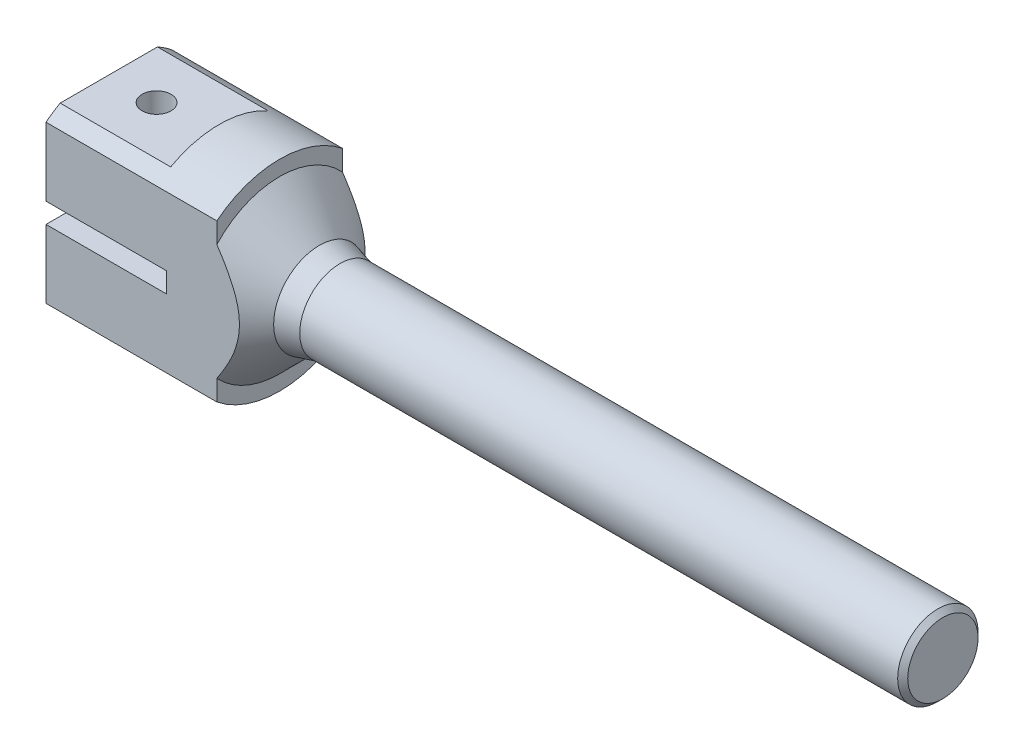
from build123d import *

# Parameters (mm, degrees)
SKIZZE2_W                       = 22
SKIZZE2_H                       = 2.5
SKIZZE2_W_2                     = 24
SKIZZE2_H_2                     = 4
SCHNITT_LINEAR_AUSTRAGEN1_DEPTH = 50
SKIZZE3_R                       = 2.875
SKIZZE3_W                       = 38.5
SKIZZE3_H                       = 7.5
SCHNITT_LINEAR_AUSTRAGEN2_DEPTH = 38.5
FASE1_SIZE                      = 1


with BuildPart() as part:
    # Skizze1 → Rotation1 (revolve)
    with BuildSketch(Plane.XY, mode=Mode.PRIVATE) as rotation1_sk:
        Polygon((0, 0), (0, 8), (-120, 8), (-124.098076211, 9.098076211), (-132, 17), (-132, 20), (-166, 20), (-166, 0), align=None)
    revolve(rotation1_sk.sketch.rotate(Axis((0, 0, 0), (1, 0, 0)), 90), axis=Axis((0, 0, 0), (1, 0, 0)))  # turned: the seam where the file's is

    # Skizze2 → Schnitt-Linear austragen1 (cut, symmetric)
    with BuildSketch(Plane.XY):
        with Locations((-155, 18.75)):
            Rectangle(SKIZZE2_W, SKIZZE2_H)
        with Locations((-154, 0)):
            Rectangle(SKIZZE2_W_2, SKIZZE2_H_2)
        with Locations((-155, -18.75)):
            Rectangle(SKIZZE2_W, SKIZZE2_H)
    extrude(amount=SCHNITT_LINEAR_AUSTRAGEN1_DEPTH, both=True, mode=Mode.SUBTRACT)

    # Skizze3 → Schnitt-Linear austragen2 (cut, through all)
    with BuildSketch(Plane(origin=(0, 17.5, 0), x_dir=(1, 0, 0), z_dir=(0, 1, 0))):
        with Locations(Location((-156.5, 0, 0), (0, 0, 270))):  # turned: the seam where the file's is
            Circle(SKIZZE3_R)
        with Locations((-146.75, -16.25)):
            Rectangle(SKIZZE3_W, SKIZZE3_H)
        with Locations((-146.75, 16.25)):
            Rectangle(SKIZZE3_W, SKIZZE3_H)
    extrude(amount=-SCHNITT_LINEAR_AUSTRAGEN2_DEPTH, mode=Mode.SUBTRACT)

    # Fase1
    fase1_edges = [part.edges().sort_by_distance(p)[0] for p in [
        (0, 0, -8),
    ]]
    chamfer(fase1_edges, length=FASE1_SIZE)


solid = part.part
